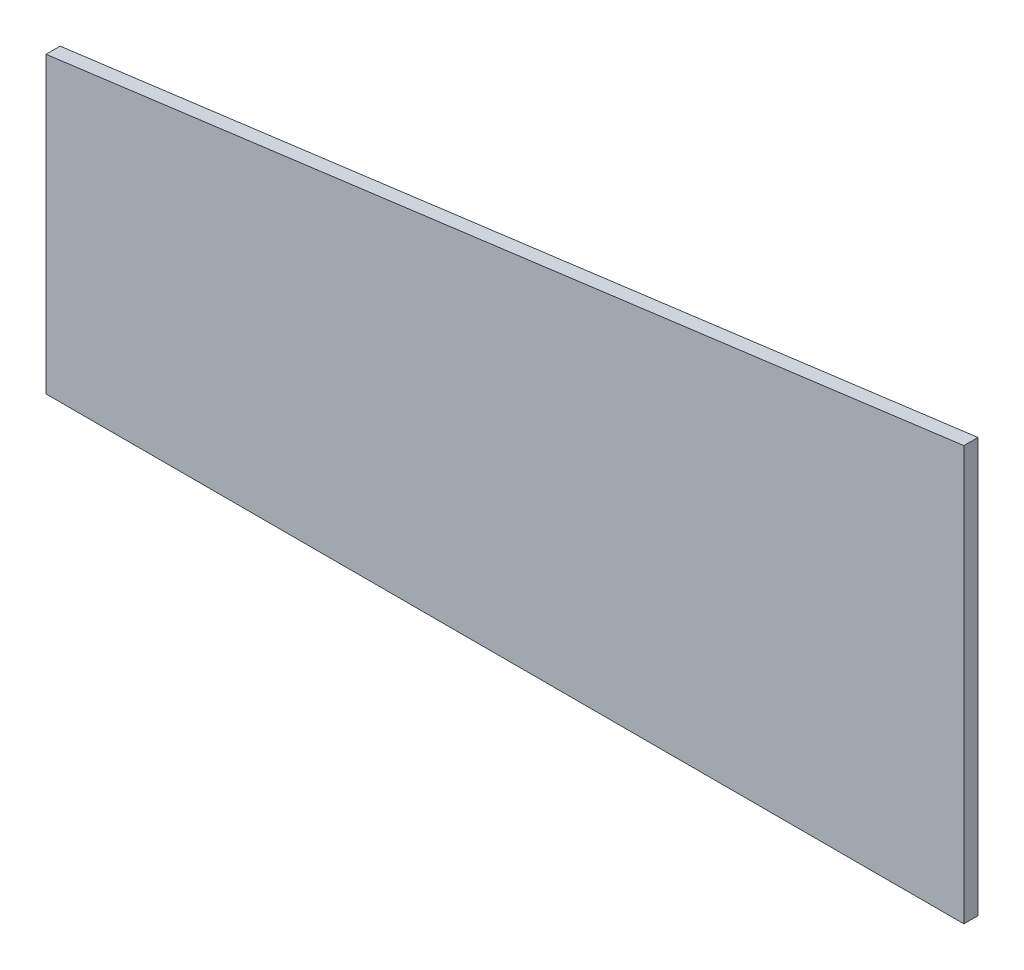
from build123d import *

# Parameters (mm, degrees)
EXTRUDE1_DEPTH = 19.05


with BuildPart() as part:
    # Sketch1 → Extrude1 (new body)
    with BuildSketch(Plane.XY):
        Polygon((-865.1875, -3611.5625), (-865.1875, -3214.6875), (373.0625, -3052.772490816), (373.0625, -3611.5625), align=None)
    extrude(amount=EXTRUDE1_DEPTH)


solid = part.part
